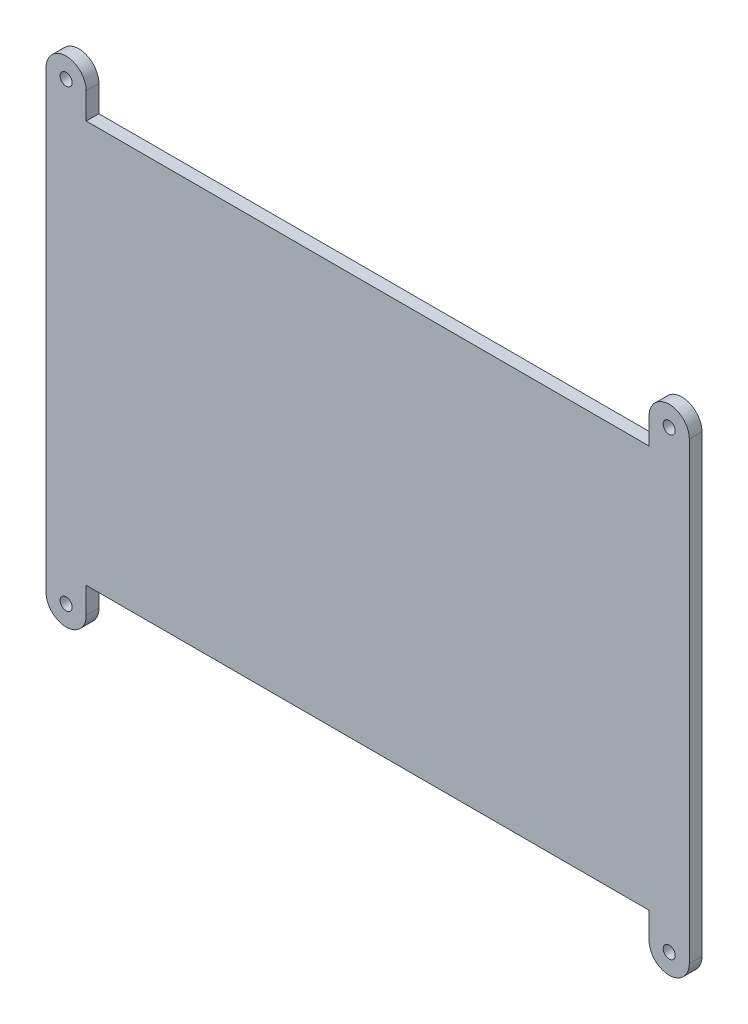
from build123d import *

# Parameters (mm, degrees)
BOSS_EXTRUDE1_DEPTH = 1.6
SKETCH2_R           = 0.762
CUT_EXTRUDE1_DEPTH  = 2.6


with BuildPart() as part:
    # Sketch1 → Boss-Extrude1 (new body)
    with BuildSketch(Plane.XY):
        with BuildLine():
            Line((-35.56, 25.4), (35.56, 25.4))
            Line((35.56, 25.4), (35.56, 28.702))
            ThreePointArc((35.56, 28.702), (38.1, 31.242), (40.64, 28.702))
            Line((40.64, 28.702), (40.64, -28.702))
            ThreePointArc((40.64, -28.702), (38.1, -31.242), (35.56, -28.702))
            Line((35.56, -28.702), (35.56, -25.4))
            Line((35.56, -25.4), (-35.56, -25.4))
            Line((-35.56, -25.4), (-35.56, -28.702))
            ThreePointArc((-35.56, -28.702), (-38.1, -31.242), (-40.64, -28.702))
            Line((-40.64, -28.702), (-40.64, 28.702))
            ThreePointArc((-40.64, 28.702), (-38.1, 31.242), (-35.56, 28.702))
            Line((-35.56, 28.702), (-35.56, 25.4))
        make_face()
    extrude(amount=BOSS_EXTRUDE1_DEPTH)

    # Sketch2 → Cut-Extrude1 (cut, through all)
    with BuildSketch(Plane.XY.offset(1.6)):
        with Locations((38.1, 28.702)):
            Circle(SKETCH2_R)
        with Locations((-38.1, 28.702)):
            Circle(SKETCH2_R)
        with Locations((38.1, -28.702)):
            Circle(SKETCH2_R)
        with Locations((-38.1, -28.702)):
            Circle(SKETCH2_R)
    extrude(amount=-CUT_EXTRUDE1_DEPTH, mode=Mode.SUBTRACT)


solid = part.part
